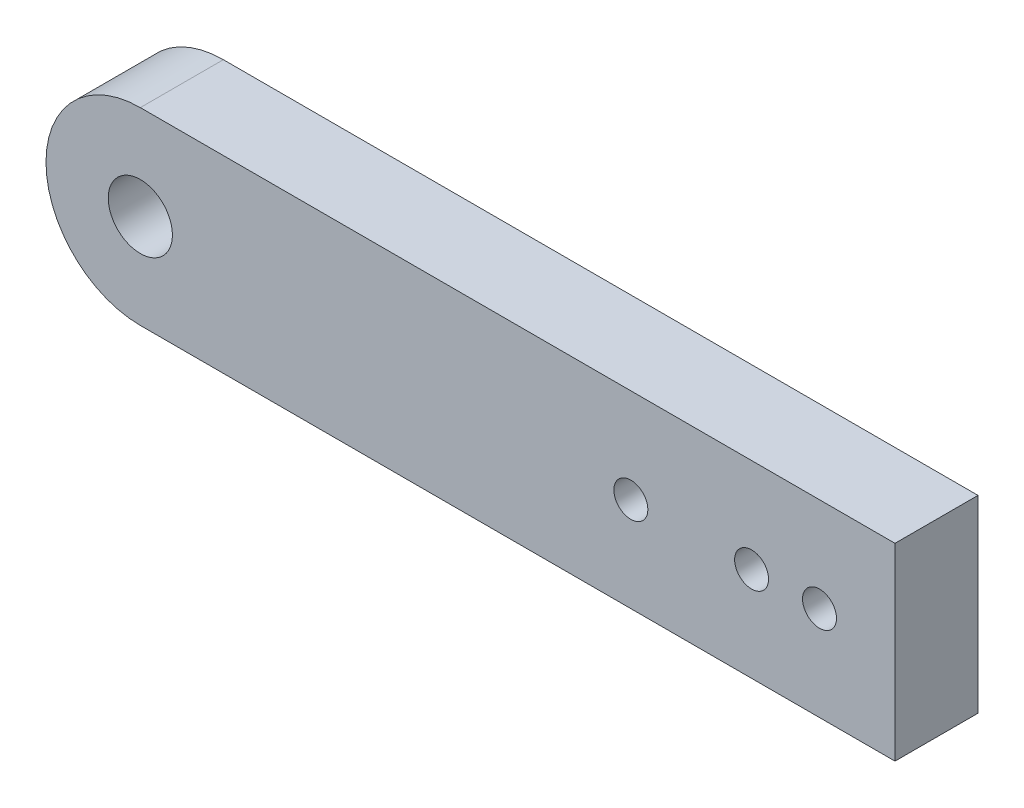
from build123d import *

# Parameters (mm, degrees)
SKETCH_1_R      = 2.25
SKETCH_1_R_2    = 4.25
EXTRUDE_1_DEPTH = 11


with BuildPart() as part:
    # 草图1 → 凸台-拉伸1 (new body)
    with BuildSketch(Plane.XY):
        with BuildLine():
            Line((-56.82826087, 9.961271461), (43.17173913, 9.961271461))
            Line((43.17173913, 9.961271461), (43.17173913, -15.038728539))
            Line((43.17173913, -15.038728539), (-56.82826087, -15.038728539))
            ThreePointArc((-56.82826087, -15.038728539), (-69.32826087, -2.538728539), (-56.82826087, 9.961271461))
        make_face()
        with Locations((33.17173913, -2.538728539)):
            Circle(SKETCH_1_R, mode=Mode.SUBTRACT)
        with Locations((24.17173913, -2.538728539)):
            Circle(SKETCH_1_R, mode=Mode.SUBTRACT)
        with Locations((8.17173913, -2.538728539)):
            Circle(SKETCH_1_R, mode=Mode.SUBTRACT)
        with Locations((-56.82826087, -2.538728539)):
            Circle(SKETCH_1_R_2, mode=Mode.SUBTRACT)
    extrude(amount=EXTRUDE_1_DEPTH)


solid = part.part
